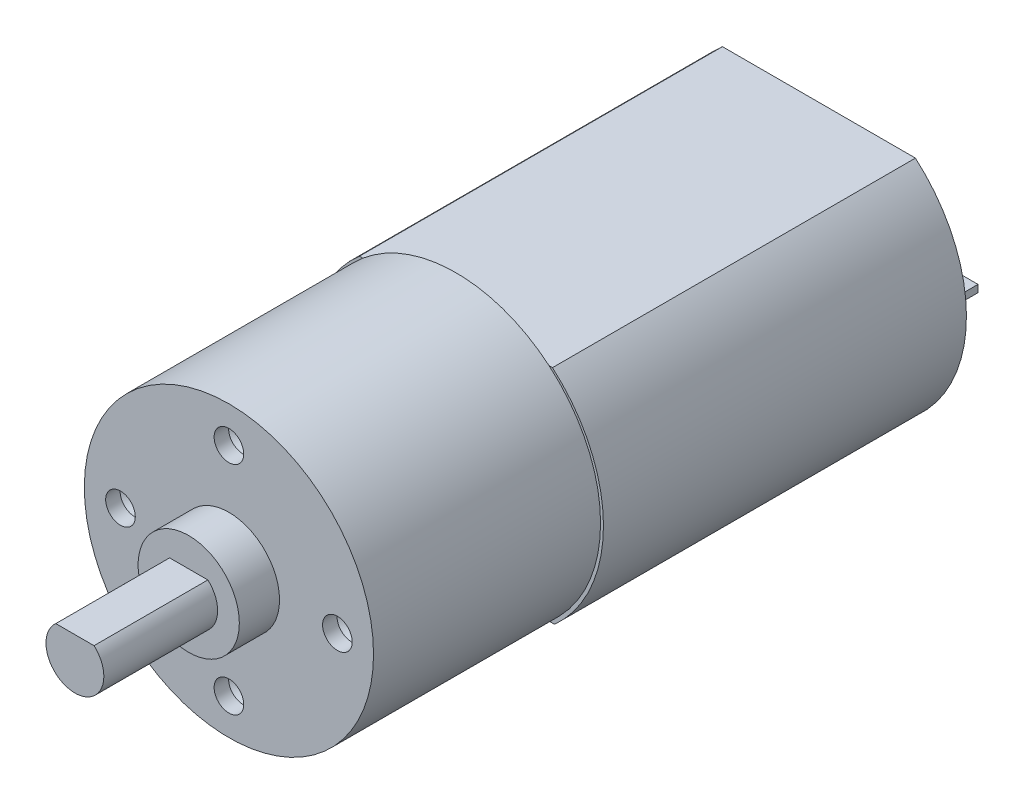
from build123d import *

# Parameters (mm, degrees)
SKETCH1_R                    = 10
GEARBOX_DEPTH                = 15.7
MOTOR_DEPTH                  = 25.1
SKETCH4_R                    = 3.5
OUTPUT_SHAFT_COLLAR_DEPTH    = 2.78
OUTPUT_SHAFT_DEPTH           = 7.87
SKETCH6_R                    = 3.02
BOSS_EXTRUDE11_DEPTH         = 1.86
SKETCH10_W                   = 2.36
SKETCH10_H                   = 0.5
BOSS_EXTRUDE13_DEPTH         = 2
M2_5X0_45_TAPPED_HOLE1_D     = 2.05
M2_5X0_45_TAPPED_HOLE1_DEPTH = 1
M2_5X0_45_TAPPED_HOLE1_TIP   = 0.615882135


with BuildPart() as part:
    # Sketch1 → GearBox (new body)
    with BuildSketch(Plane.XY):
        Circle(SKETCH1_R)
    extrude(amount=GEARBOX_DEPTH)

    # Sketch3 → Motor (add)
    with BuildSketch(Plane(origin=(0, 0, 0), x_dir=(-1, 0, 0), z_dir=(0, 0, -1))):
        with BuildLine():
            Line((-6.674371666, 7.65), (6.674371666, 7.65))
            ThreePointArc((6.674371666, 7.65), (10.2, 0.032634765), (6.818960021, -7.65))
            Line((6.818960021, -7.65), (-6.818960021, -7.65))
            ThreePointArc((-6.818960021, -7.65), (-10.2, 0.032634765), (-6.674371666, 7.65))
        make_face()
    extrude(amount=MOTOR_DEPTH)

    # Sketch4 → Output_Shaft_Collar (add)
    with BuildSketch(Plane.XY.offset(15.7)):
        Circle(SKETCH4_R)
    extrude(amount=OUTPUT_SHAFT_COLLAR_DEPTH)

    # Sketch5 → Output_Shaft (add)
    with BuildSketch(Plane.XY.offset(18.48)):
        with BuildLine():
            Line((-1.322875656, 1.5), (1.322875656, 1.5))
            ThreePointArc((1.322875656, 1.5), (0, -2), (-1.322875656, 1.5))
        make_face()
    extrude(amount=OUTPUT_SHAFT_DEPTH)

    # Sketch6 → Boss-Extrude11 (add)
    with BuildSketch(Plane(origin=(0, 0, -25.1), x_dir=(-1, 0, 0), z_dir=(0, 0, -1))):
        Circle(SKETCH6_R)
    extrude(amount=BOSS_EXTRUDE11_DEPTH)

    # Sketch10 → Boss-Extrude13 (add)
    with BuildSketch(Plane(origin=(0, 0, -25.1), x_dir=(-1, 0, 0), z_dir=(0, 0, -1))):
        with Locations((-7.82, 0)):
            Rectangle(SKETCH10_W, SKETCH10_H)
        with Locations((7.82, 0)):
            Rectangle(SKETCH10_W, SKETCH10_H)
    extrude(amount=BOSS_EXTRUDE13_DEPTH)

    # M2.5x0.45 Tapped Hole1
    with Locations(Plane.XY.offset(15.7)):
        with Locations((-7.5, 0), (7.5, 0), (0, 7.5), (0, -7.5)):
            Hole(M2_5X0_45_TAPPED_HOLE1_D / 2, depth=M2_5X0_45_TAPPED_HOLE1_DEPTH)
            with Locations((0, 0, -(M2_5X0_45_TAPPED_HOLE1_DEPTH + M2_5X0_45_TAPPED_HOLE1_TIP / 2))):  # 118° drill point
                Cone(0, M2_5X0_45_TAPPED_HOLE1_D / 2, M2_5X0_45_TAPPED_HOLE1_TIP, mode=Mode.SUBTRACT)


solid = part.part
